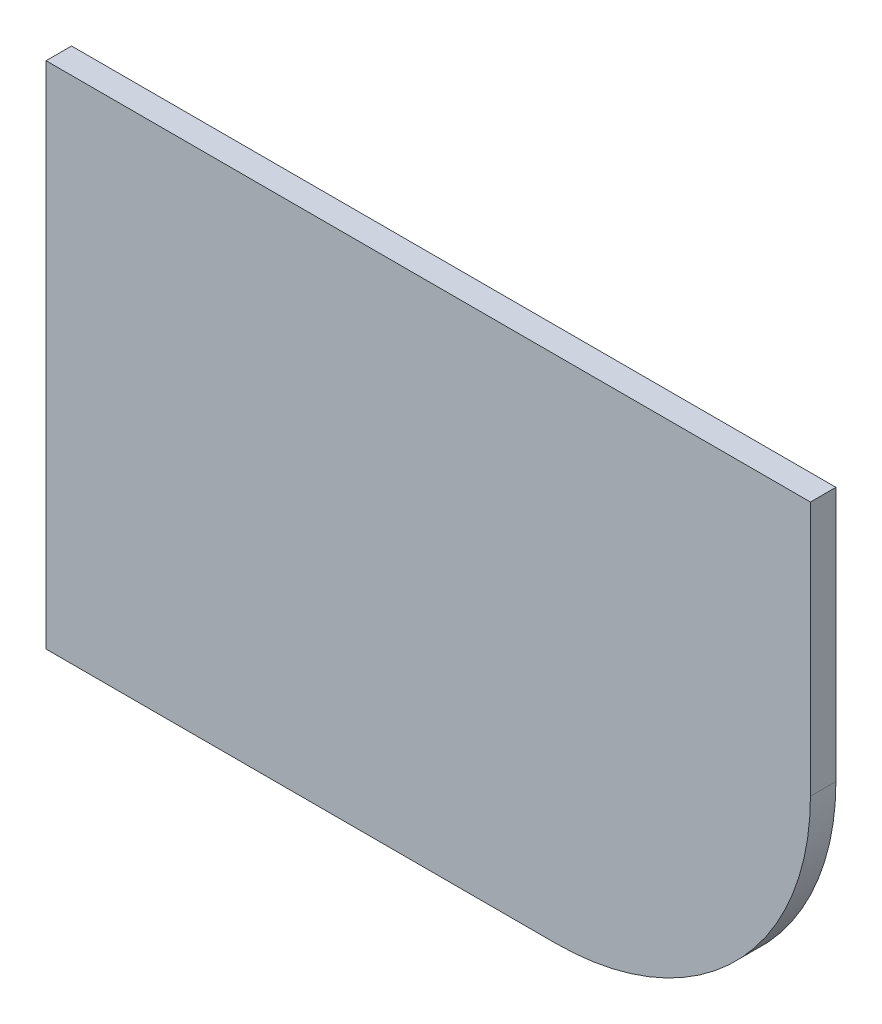
from build123d import *

# Parameters (mm, degrees)
BOSS_EXTRUDE1_DEPTH = 5
SKETCH6_R           = 2.5
CUT_EXTRUDE1_DEPTH  = 5


with BuildPart() as part:
    # Sketch1 → Boss-Extrude1 (new body, symmetric)
    with BuildSketch(Plane.XY):
        with BuildLine():
            Line((0, 200), (0, 0))
            Line((0, 0), (200, 0))
            ThreePointArc((200, 0), (270.710678119, 29.289321881), (300, 100))
            Line((300, 100), (300, 200))
            Line((300, 200), (0, 200))
        make_face()
    extrude(amount=BOSS_EXTRUDE1_DEPTH, both=True)

    # Sketch6 → Cut-Extrude1 (cut)
    with BuildSketch(Plane(origin=(0, 0, -5), x_dir=(-1, 0, 0), z_dir=(0, 0, -1))):
        with Locations((-225, 140)):
            Circle(SKETCH6_R)
        with Locations((-150, 90)):
            Circle(SKETCH6_R)
        with Locations((-60, 140)):
            Circle(SKETCH6_R)
        with Locations((-75, 40)):
            Circle(SKETCH6_R)
    extrude(amount=-CUT_EXTRUDE1_DEPTH, mode=Mode.SUBTRACT)


solid = part.part
